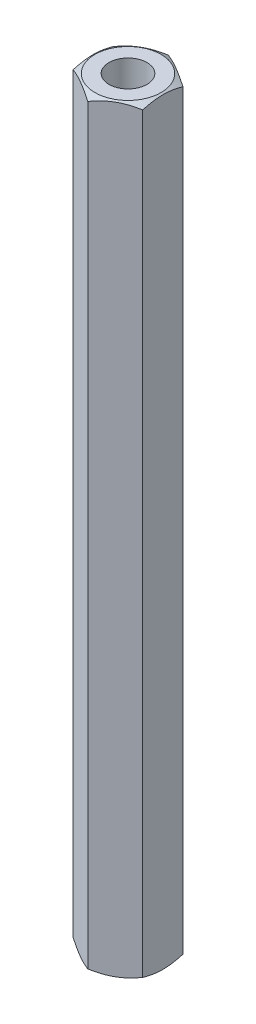
from build123d import *

# Parameters (mm, degrees)
SKETCH_1_R      = 1.5
EXTRUDE_1_DEPTH = 60


with BuildPart() as part:
    # Эскиз1 → Бобышка-Вытянуть1 (new body)
    with BuildSketch(Plane(origin=(0, 0, 0), x_dir=(1, 0, 0), z_dir=(0, 1, 0))):
        Polygon((0, 3.175426481), (-2.75, 1.58771324), (-2.75, -1.58771324), (0, -3.175426481), (2.75, -1.58771324), (2.75, 1.58771324), align=None)
        Circle(SKETCH_1_R, mode=Mode.SUBTRACT)
    extrude(amount=EXTRUDE_1_DEPTH)

    # Эскиз3 → Вырез-Повернуть1 (revolve, cut)
    with BuildSketch(Plane(origin=(0, 0, 0), x_dir=(0, 0, -1), z_dir=(1, 0, 0))):
        Polygon((-8.378043736, 3.328738228), (-8.378043736, 0), (-2.6125, 0), align=None)
        Polygon((-11.931875613, 60), (-2.6125, 60), (-11.931875613, 54.619455981), align=None)
    revolve(axis=Axis((0, 60, 0), (0, -1, 0)), mode=Mode.SUBTRACT)


solid = part.part
